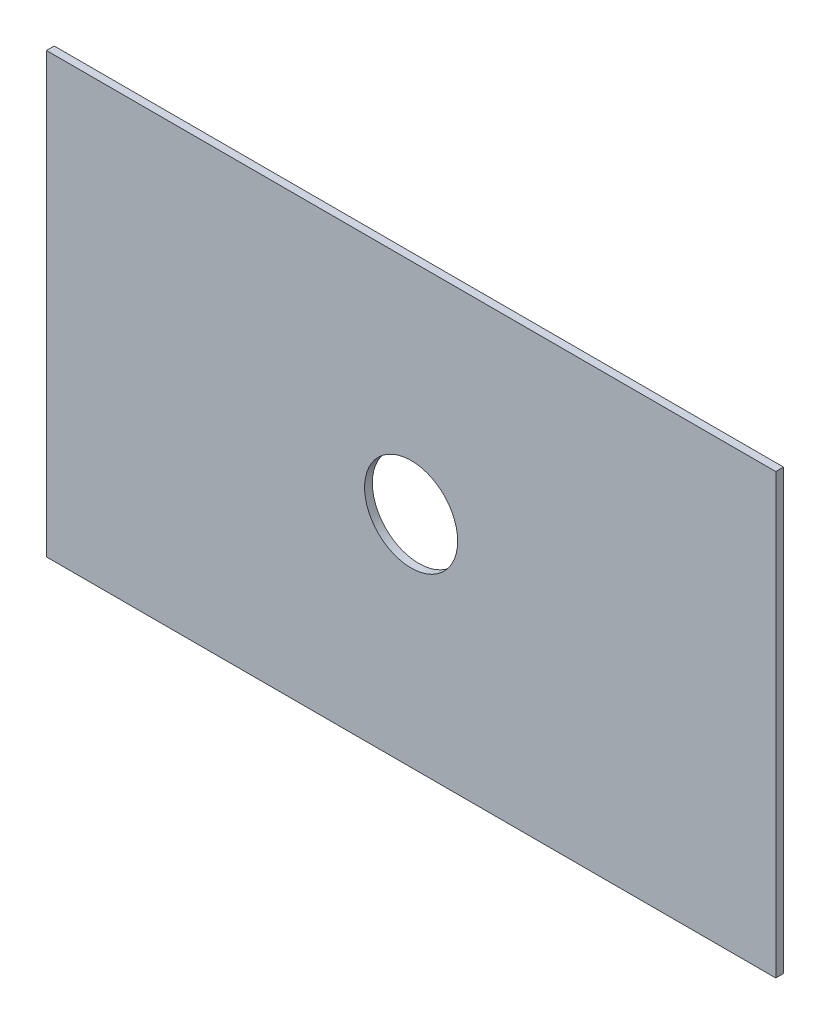
from build123d import *

# Parameters (mm, degrees)
SCHIZZO2_W                   = 47.000299234
SCHIZZO2_H                   = 28.266419926
ESTRUSIONE_ESTRUSIONE1_DEPTH = 0.5
SCHIZZO3_R                   = 3
TAGLIO_ESTRUSIONE1_DEPTH     = 1


with BuildPart() as part:
    # Schizzo2 → Estrusione-Estrusione1 (new body)
    with BuildSketch(Plane.XY):
        Rectangle(SCHIZZO2_W, SCHIZZO2_H)
    extrude(amount=ESTRUSIONE_ESTRUSIONE1_DEPTH)

    # Schizzo3 → Taglio-Estrusione1 (cut)
    with BuildSketch(Plane.XY.offset(0.5)):
        Circle(SCHIZZO3_R)
    extrude(amount=-TAGLIO_ESTRUSIONE1_DEPTH, mode=Mode.SUBTRACT)


solid = part.part
